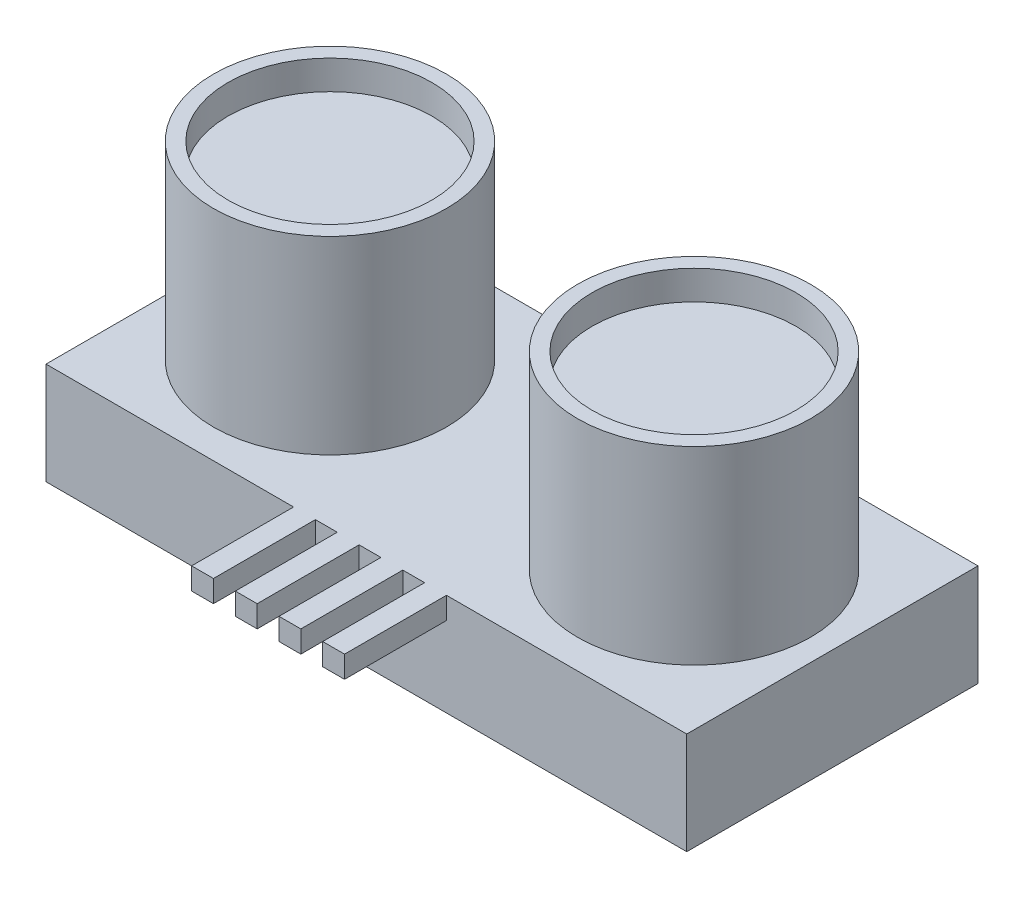
from build123d import *

# Parameters (mm, degrees)
SKETCH1_W           = 44
SKETCH1_H           = 20
BOSS_EXTRUDE1_DEPTH = 7
SKETCH3_R           = 8
BOSS_EXTRUDE2_DEPTH = 13
SKETCH4_R           = 7
CUT_EXTRUDE1_DEPTH  = 2
SKETCH5_W           = 1.5
SKETCH5_H           = 1.5
BOSS_EXTRUDE3_DEPTH = 7


with BuildPart() as part:
    # Sketch1 → Boss-Extrude1 (new body)
    with BuildSketch(Plane(origin=(0, 0, 0), x_dir=(1, 0, 0), z_dir=(0, 1, 0))):
        with Locations((-3.680933852, 5.151750973)):
            Rectangle(SKETCH1_W, SKETCH1_H)
    extrude(amount=BOSS_EXTRUDE1_DEPTH)

    # Sketch3 → Boss-Extrude2 (add)
    with BuildSketch(Plane(origin=(0, 7, 0), x_dir=(1, 0, 0), z_dir=(0, 1, 0))):
        with Locations((-16.180933852, 5.151750973)):
            Circle(SKETCH3_R)
        with Locations((8.819066148, 5.151750973)):
            Circle(SKETCH3_R)
    extrude(amount=BOSS_EXTRUDE2_DEPTH)

    # Sketch4 → Cut-Extrude1 (cut)
    with BuildSketch(Plane(origin=(0, 20, 0), x_dir=(1, 0, 0), z_dir=(0, 1, 0))):
        with Locations((-16.180933852, 5.151750973)):
            Circle(SKETCH4_R)
        with Locations((8.819066148, 5.151750973)):
            Circle(SKETCH4_R)
    extrude(amount=-CUT_EXTRUDE1_DEPTH, mode=Mode.SUBTRACT)

    # Sketch5 → Boss-Extrude3 (add)
    with BuildSketch(Plane.XY.offset(4.848249027)):
        with Locations((-7.930933852, 6.25)):
            Rectangle(SKETCH5_W, SKETCH5_H)
        with Locations((-4.930933852, 6.25)):
            Rectangle(SKETCH5_W, SKETCH5_H)
        with Locations((-1.930933852, 6.25)):
            Rectangle(SKETCH5_W, SKETCH5_H)
        with Locations((1.069066148, 6.25)):
            Rectangle(SKETCH5_W, SKETCH5_H)
    extrude(amount=BOSS_EXTRUDE3_DEPTH)


solid = part.part
